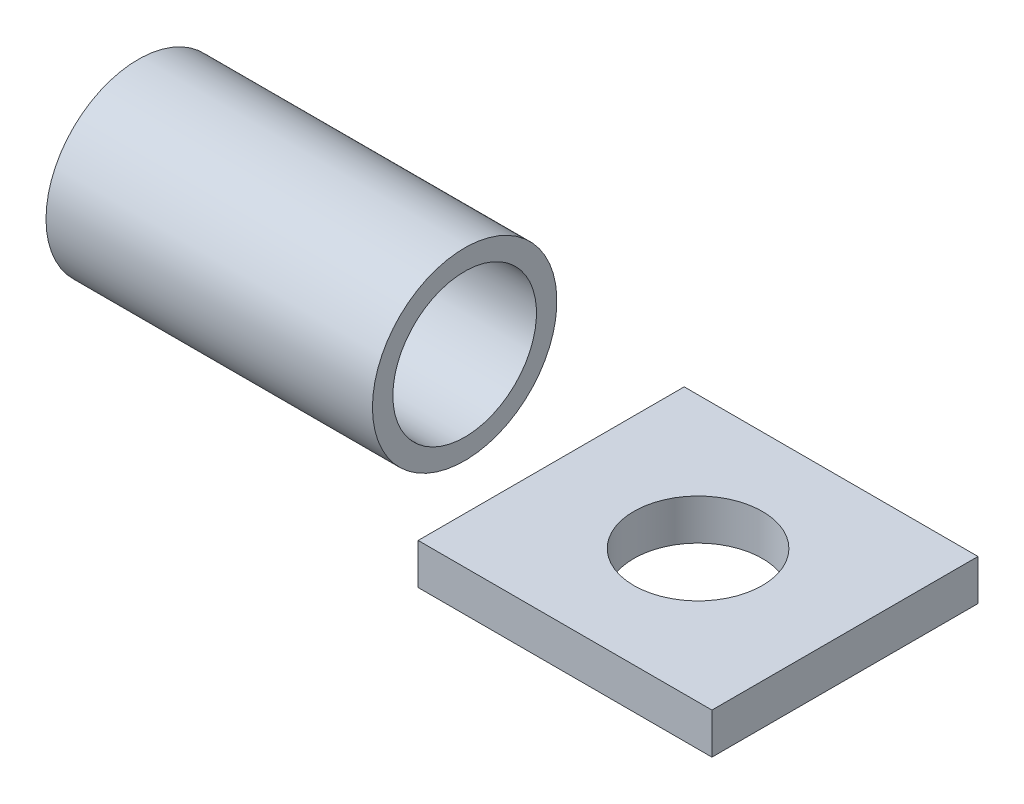
from build123d import *

# Parameters (mm, degrees)
SKETCH1_W           = 22.86
SKETCH1_H           = 20.701
SKETCH1_R           = 5
BOSS_EXTRUDE1_DEPTH = 3.175
SKETCH2_R           = 7.1755
SKETCH2_R_2         = 5.588
EXTRUDE_THIN1_DEPTH = 25.4


with BuildPart() as part:
    # Sketch1 → Boss-Extrude1 (new body)
    with BuildSketch(Plane(origin=(0, 0, 0), x_dir=(1, 0, 0), z_dir=(0, 1, 0))):
        Rectangle(SKETCH1_W, SKETCH1_H)
        Circle(SKETCH1_R, mode=Mode.SUBTRACT)
    extrude(amount=BOSS_EXTRUDE1_DEPTH)


with BuildPart() as body_2:
    # Sketch2 → Extrude-Thin1 (new body)
    with BuildSketch(Plane.ZY.offset(43.561)):
        with Locations((0, 7.1755)):
            Circle(SKETCH2_R)
        with Locations((0, 7.1755)):
            Circle(SKETCH2_R_2, mode=Mode.SUBTRACT)
    extrude(amount=-EXTRUDE_THIN1_DEPTH)


solid = Compound([part.part, body_2.part])
